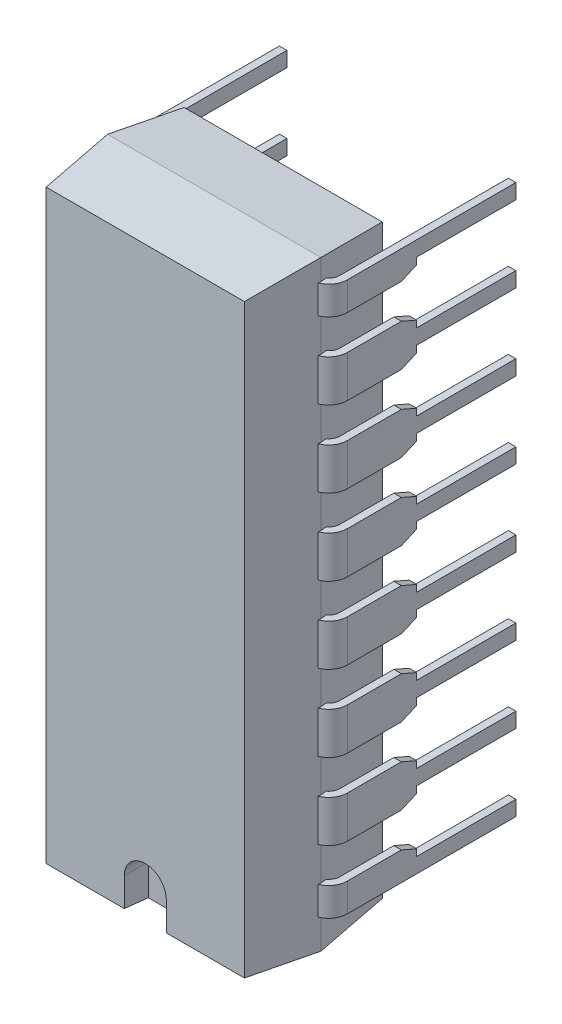
from build123d import *

# Parameters (mm, degrees)
BASIC_SHAPE_DEPTH              = 10
SIDE_PROFILE1_DEPTH            = 4.55
SIDE_PROFILE1_DEPTH_BACK       = 4.55
SIDE_PROFILE2_DEPTH            = 4.55
SIDE_PROFILE2_DEPTH_BACK       = 4.55
LOCATION_MARK_DEPTH            = 0.8
SKETCH6_W                      = 0.25
SKETCH6_H                      = 1.39
PIN_RELIEF_DEPTH               = 1.25
REMAINING_PINS_COUNT           = 8
REMAINING_PINS_PITCH           = 2.54
REMAINING_PINS_COPY_1_SKETCH_W = 0.25
REMAINING_PINS_COPY_1_SKETCH_H = 1.39
REMAINING_PINS_COPY_2_SKETCH_W = 0.25
REMAINING_PINS_COPY_2_SKETCH_H = 1.39
REMAINING_PINS_COPY_3_SKETCH_W = 0.25
REMAINING_PINS_COPY_3_SKETCH_H = 1.39
REMAINING_PINS_COPY_4_SKETCH_W = 0.25
REMAINING_PINS_COPY_4_SKETCH_H = 1.39
REMAINING_PINS_COPY_5_SKETCH_W = 0.25
REMAINING_PINS_COPY_5_SKETCH_H = 1.39
REMAINING_PINS_COPY_6_SKETCH_W = 0.25
REMAINING_PINS_COPY_6_SKETCH_H = 1.39
REMAINING_PINS_COPY_7_SKETCH_W = 0.25
REMAINING_PINS_COPY_7_SKETCH_H = 1.39
REMAINING_PINS_COPY_8_DEPTH    = 1.25
REMAINING_PINS_COPY_9_DEPTH    = 1.25
REMAINING_PINS_COPY_10_DEPTH   = 1.25
REMAINING_PINS_COPY_11_DEPTH   = 1.25
REMAINING_PINS_COPY_12_DEPTH   = 1.25
REMAINING_PINS_COPY_13_DEPTH   = 1.25
REMAINING_PINS_COPY_14_DEPTH   = 1.25
PIN_RELIEF1_DEPTH              = 0.445
PIN_RELIEF2_DEPTH              = 0.445


with BuildPart() as part:
    # Sketch1 → Basic Shape (new body, symmetric)
    with BuildSketch(Plane(origin=(0, 0, 0), x_dir=(1, 0, 0), z_dir=(0, 1, 0))):
        Polygon((-3.3, -5.1), (-3.55, -2.805), (-3.3, -0.51), (3.3, -0.51), (3.55, -2.805), (3.3, -5.1), align=None)
    extrude(amount=BASIC_SHAPE_DEPTH, both=True)

    # Sketch2 → Side Profile1 (cut, two sides)
    with BuildSketch(Plane(origin=(0, 0, 0), x_dir=(0, 0, -1), z_dir=(1, 0, 0))) as side_profile1_sk:
        Polygon((-0.51, 10), (-0.51, 9.75), (-2.805, 10), align=None)
        Polygon((-0.51, -10), (-2.805, -10), (-0.51, -9.75), align=None)
    extrude(amount=SIDE_PROFILE1_DEPTH, mode=Mode.SUBTRACT)
    extrude(side_profile1_sk.sketch, amount=-SIDE_PROFILE1_DEPTH_BACK, mode=Mode.SUBTRACT)

    # Sketch3 → Side Profile2 (cut, two sides)
    with BuildSketch(Plane(origin=(0, 0, 0), x_dir=(0, 0, -1), z_dir=(1, 0, 0))) as side_profile2_sk:
        Polygon((-2.805, 10), (-5.1, 10), (-5.1, 9.75), align=None)
        Polygon((-2.805, -10), (-5.1, -10), (-5.1, -9.75), align=None)
    extrude(amount=SIDE_PROFILE2_DEPTH, mode=Mode.SUBTRACT)
    extrude(side_profile2_sk.sketch, amount=-SIDE_PROFILE2_DEPTH_BACK, mode=Mode.SUBTRACT)

    # Sketch4 → Location Mark (cut)
    with BuildSketch(Plane.XY.offset(5.1)):
        with BuildLine():
            Line((-0.7, -10), (-0.7, -8.8))
            ThreePointArc((-0.7, -8.8), (0, -8.1), (0.7, -8.8))
            Line((0.7, -8.8), (0.7, -10))
            Line((0.7, -10), (-0.7, -10))
        make_face()
    extrude(amount=-LOCATION_MARK_DEPTH, mode=Mode.SUBTRACT)

    # First Pin: sweep along a path in Sketch5
    with BuildLine(Plane(origin=(0, -8.73, 0), x_dir=(1, 0, 0), z_dir=(0, 1, 0))) as first_pin_path:
        Line((0, -2.805), (3.31, -2.805))
        ThreePointArc((3.31, -2.805), (3.663553391, -2.658553391), (3.81, -2.305))
        Line((3.81, -2.305), (3.81, 3.3))
    # Sketch6 → First Pin (sweep)
    with BuildSketch(Plane(origin=(0, 0, 0), x_dir=(0, 0, -1), z_dir=(1, 0, 0))):
        with Locations((-2.805, -8.73)):
            Rectangle(SKETCH6_W, SKETCH6_H)
    first_pin = sweep(path=first_pin_path.line)

    # Sketch7 → Pin Relief (cut, through all)
    with BuildSketch(Plane.ZY.offset(-3.685)):
        Polygon((-3.3, -8.98), (0, -8.98), (0, -9.2025), (0.51, -9.425), (-3.3, -9.425), align=None)
        Polygon((-3.3, -8.48), (0, -8.48), (0, -8.2575), (0.51, -8.035), (-3.3, -8.035), align=None)
    pin_relief = extrude(amount=-PIN_RELIEF_DEPTH, mode=Mode.SUBTRACT)

    # Opp Pin: First Pin, Pin Relief across plane
    add(first_pin.mirror(Plane(origin=(0, 0, 0), x_dir=(0, 0, 1), z_dir=(1, 0, 0))))
    add(pin_relief.mirror(Plane(origin=(0, 0, 0), x_dir=(0, 0, 1), z_dir=(1, 0, 0))), mode=Mode.SUBTRACT)

    # Remaining Pins: First Pin, Pin Relief ×8
    with Locations(*[(0, i * REMAINING_PINS_PITCH, 0) for i in range(1, REMAINING_PINS_COUNT)]):
        add(first_pin)
        add(pin_relief, mode=Mode.SUBTRACT)

    # Remaining Pins copy 1: sweep along a path in Remaining Pins copy 1 path
    with BuildLine(Plane(origin=(0, -6.19, 0), x_dir=(-1, 0, 0), z_dir=(0, 1, 0))) as remaining_pins_copy_1_path:
        Line((0, 2.805), (3.31, 2.805))
        ThreePointArc((3.31, 2.805), (3.663553391, 2.658553391), (3.81, 2.305))
        Line((3.81, 2.305), (3.81, -3.3))
    # Remaining Pins copy 1 sketch → Remaining Pins copy 1 (sweep)
    with BuildSketch(Plane(origin=(0, 2.54, 0), x_dir=(0, 0, -1), z_dir=(-1, 0, 0))):
        with Locations((-2.805, 8.73)):
            Rectangle(REMAINING_PINS_COPY_1_SKETCH_W, REMAINING_PINS_COPY_1_SKETCH_H)
    sweep(path=remaining_pins_copy_1_path.line)

    # Remaining Pins copy 2: sweep along a path in Remaining Pins copy 2 path
    with BuildLine(Plane(origin=(0, -3.65, 0), x_dir=(-1, 0, 0), z_dir=(0, 1, 0))) as remaining_pins_copy_2_path:
        Line((0, 2.805), (3.31, 2.805))
        ThreePointArc((3.31, 2.805), (3.663553391, 2.658553391), (3.81, 2.305))
        Line((3.81, 2.305), (3.81, -3.3))
    # Remaining Pins copy 2 sketch → Remaining Pins copy 2 (sweep)
    with BuildSketch(Plane(origin=(0, 5.08, 0), x_dir=(0, 0, -1), z_dir=(-1, 0, 0))):
        with Locations((-2.805, 8.73)):
            Rectangle(REMAINING_PINS_COPY_2_SKETCH_W, REMAINING_PINS_COPY_2_SKETCH_H)
    sweep(path=remaining_pins_copy_2_path.line)

    # Remaining Pins copy 3: sweep along a path in Remaining Pins copy 3 path
    with BuildLine(Plane(origin=(0, -1.11, 0), x_dir=(-1, 0, 0), z_dir=(0, 1, 0))) as remaining_pins_copy_3_path:
        Line((0, 2.805), (3.31, 2.805))
        ThreePointArc((3.31, 2.805), (3.663553391, 2.658553391), (3.81, 2.305))
        Line((3.81, 2.305), (3.81, -3.3))
    # Remaining Pins copy 3 sketch → Remaining Pins copy 3 (sweep)
    with BuildSketch(Plane(origin=(0, 7.62, 0), x_dir=(0, 0, -1), z_dir=(-1, 0, 0))):
        with Locations((-2.805, 8.73)):
            Rectangle(REMAINING_PINS_COPY_3_SKETCH_W, REMAINING_PINS_COPY_3_SKETCH_H)
    sweep(path=remaining_pins_copy_3_path.line)

    # Remaining Pins copy 4: sweep along a path in Remaining Pins copy 4 path
    with BuildLine(Plane(origin=(0, 1.43, 0), x_dir=(-1, 0, 0), z_dir=(0, 1, 0))) as remaining_pins_copy_4_path:
        Line((0, 2.805), (3.31, 2.805))
        ThreePointArc((3.31, 2.805), (3.663553391, 2.658553391), (3.81, 2.305))
        Line((3.81, 2.305), (3.81, -3.3))
    # Remaining Pins copy 4 sketch → Remaining Pins copy 4 (sweep)
    with BuildSketch(Plane(origin=(0, 10.16, 0), x_dir=(0, 0, -1), z_dir=(-1, 0, 0))):
        with Locations((-2.805, 8.73)):
            Rectangle(REMAINING_PINS_COPY_4_SKETCH_W, REMAINING_PINS_COPY_4_SKETCH_H)
    sweep(path=remaining_pins_copy_4_path.line)

    # Remaining Pins copy 5: sweep along a path in Remaining Pins copy 5 path
    with BuildLine(Plane(origin=(0, 3.97, 0), x_dir=(-1, 0, 0), z_dir=(0, 1, 0))) as remaining_pins_copy_5_path:
        Line((0, 2.805), (3.31, 2.805))
        ThreePointArc((3.31, 2.805), (3.663553391, 2.658553391), (3.81, 2.305))
        Line((3.81, 2.305), (3.81, -3.3))
    # Remaining Pins copy 5 sketch → Remaining Pins copy 5 (sweep)
    with BuildSketch(Plane(origin=(0, 12.7, 0), x_dir=(0, 0, -1), z_dir=(-1, 0, 0))):
        with Locations((-2.805, 8.73)):
            Rectangle(REMAINING_PINS_COPY_5_SKETCH_W, REMAINING_PINS_COPY_5_SKETCH_H)
    sweep(path=remaining_pins_copy_5_path.line)

    # Remaining Pins copy 6: sweep along a path in Remaining Pins copy 6 path
    with BuildLine(Plane(origin=(0, 6.51, 0), x_dir=(-1, 0, 0), z_dir=(0, 1, 0))) as remaining_pins_copy_6_path:
        Line((0, 2.805), (3.31, 2.805))
        ThreePointArc((3.31, 2.805), (3.663553391, 2.658553391), (3.81, 2.305))
        Line((3.81, 2.305), (3.81, -3.3))
    # Remaining Pins copy 6 sketch → Remaining Pins copy 6 (sweep)
    with BuildSketch(Plane(origin=(0, 15.24, 0), x_dir=(0, 0, -1), z_dir=(-1, 0, 0))):
        with Locations((-2.805, 8.73)):
            Rectangle(REMAINING_PINS_COPY_6_SKETCH_W, REMAINING_PINS_COPY_6_SKETCH_H)
    sweep(path=remaining_pins_copy_6_path.line)

    # Remaining Pins copy 7: sweep along a path in Remaining Pins copy 7 path
    with BuildLine(Plane(origin=(0, 9.05, 0), x_dir=(-1, 0, 0), z_dir=(0, 1, 0))) as remaining_pins_copy_7_path:
        Line((0, 2.805), (3.31, 2.805))
        ThreePointArc((3.31, 2.805), (3.663553391, 2.658553391), (3.81, 2.305))
        Line((3.81, 2.305), (3.81, -3.3))
    # Remaining Pins copy 7 sketch → Remaining Pins copy 7 (sweep)
    with BuildSketch(Plane(origin=(0, 17.78, 0), x_dir=(0, 0, -1), z_dir=(-1, 0, 0))):
        with Locations((-2.805, 8.73)):
            Rectangle(REMAINING_PINS_COPY_7_SKETCH_W, REMAINING_PINS_COPY_7_SKETCH_H)
    sweep(path=remaining_pins_copy_7_path.line)

    # Remaining Pins copy 8 sketch → Remaining Pins copy 8 (cut, through all)
    with BuildSketch(Plane(origin=(-3.685, 2.54, 0), x_dir=(0, 0, 1), z_dir=(1, 0, 0))):
        Polygon((-3.3, 8.98), (0, 8.98), (0, 9.2025), (0.51, 9.425), (-3.3, 9.425), align=None)
        Polygon((-3.3, 8.48), (0, 8.48), (0, 8.2575), (0.51, 8.035), (-3.3, 8.035), align=None)
    extrude(amount=-REMAINING_PINS_COPY_8_DEPTH, mode=Mode.SUBTRACT)

    # Remaining Pins copy 9 sketch → Remaining Pins copy 9 (cut, through all)
    with BuildSketch(Plane(origin=(-3.685, 5.08, 0), x_dir=(0, 0, 1), z_dir=(1, 0, 0))):
        Polygon((-3.3, 8.98), (0, 8.98), (0, 9.2025), (0.51, 9.425), (-3.3, 9.425), align=None)
        Polygon((-3.3, 8.48), (0, 8.48), (0, 8.2575), (0.51, 8.035), (-3.3, 8.035), align=None)
    extrude(amount=-REMAINING_PINS_COPY_9_DEPTH, mode=Mode.SUBTRACT)

    # Remaining Pins copy 10 sketch → Remaining Pins copy 10 (cut, through all)
    with BuildSketch(Plane(origin=(-3.685, 7.62, 0), x_dir=(0, 0, 1), z_dir=(1, 0, 0))):
        Polygon((-3.3, 8.98), (0, 8.98), (0, 9.2025), (0.51, 9.425), (-3.3, 9.425), align=None)
        Polygon((-3.3, 8.48), (0, 8.48), (0, 8.2575), (0.51, 8.035), (-3.3, 8.035), align=None)
    extrude(amount=-REMAINING_PINS_COPY_10_DEPTH, mode=Mode.SUBTRACT)

    # Remaining Pins copy 11 sketch → Remaining Pins copy 11 (cut, through all)
    with BuildSketch(Plane(origin=(-3.685, 10.16, 0), x_dir=(0, 0, 1), z_dir=(1, 0, 0))):
        Polygon((-3.3, 8.98), (0, 8.98), (0, 9.2025), (0.51, 9.425), (-3.3, 9.425), align=None)
        Polygon((-3.3, 8.48), (0, 8.48), (0, 8.2575), (0.51, 8.035), (-3.3, 8.035), align=None)
    extrude(amount=-REMAINING_PINS_COPY_11_DEPTH, mode=Mode.SUBTRACT)

    # Remaining Pins copy 12 sketch → Remaining Pins copy 12 (cut, through all)
    with BuildSketch(Plane(origin=(-3.685, 12.7, 0), x_dir=(0, 0, 1), z_dir=(1, 0, 0))):
        Polygon((-3.3, 8.98), (0, 8.98), (0, 9.2025), (0.51, 9.425), (-3.3, 9.425), align=None)
        Polygon((-3.3, 8.48), (0, 8.48), (0, 8.2575), (0.51, 8.035), (-3.3, 8.035), align=None)
    extrude(amount=-REMAINING_PINS_COPY_12_DEPTH, mode=Mode.SUBTRACT)

    # Remaining Pins copy 13 sketch → Remaining Pins copy 13 (cut, through all)
    with BuildSketch(Plane(origin=(-3.685, 15.24, 0), x_dir=(0, 0, 1), z_dir=(1, 0, 0))):
        Polygon((-3.3, 8.98), (0, 8.98), (0, 9.2025), (0.51, 9.425), (-3.3, 9.425), align=None)
        Polygon((-3.3, 8.48), (0, 8.48), (0, 8.2575), (0.51, 8.035), (-3.3, 8.035), align=None)
    extrude(amount=-REMAINING_PINS_COPY_13_DEPTH, mode=Mode.SUBTRACT)

    # Remaining Pins copy 14 sketch → Remaining Pins copy 14 (cut, through all)
    with BuildSketch(Plane(origin=(-3.685, 17.78, 0), x_dir=(0, 0, 1), z_dir=(1, 0, 0))):
        Polygon((-3.3, 8.98), (0, 8.98), (0, 9.2025), (0.51, 9.425), (-3.3, 9.425), align=None)
        Polygon((-3.3, 8.48), (0, 8.48), (0, 8.2575), (0.51, 8.035), (-3.3, 8.035), align=None)
    extrude(amount=-REMAINING_PINS_COPY_14_DEPTH, mode=Mode.SUBTRACT)

    # Sketch9 → Pin Relief1 (cut)
    with BuildSketch(Plane.XZ.offset(9.425)):
        with BuildLine():
            Line((3.935, 0), (3.685, 0))
            Line((3.685, 0), (3.685, 2.305))
            ThreePointArc((3.685, 2.305), (3.64364911, 2.476181984), (3.528715885, 2.609611821))
            Line((3.528715885, 2.609611821), (3.55, 2.805))
            Line((3.55, 2.805), (3.541213578, 2.88565935))
            ThreePointArc((3.541213578, 2.88565935), (3.827268541, 2.655796603), (3.935, 2.305))
            Line((3.935, 2.305), (3.935, 0))
        make_face()
        with BuildLine():
            Line((-3.935, 0), (-3.685, 0))
            Line((-3.685, 0), (-3.685, 2.305))
            ThreePointArc((-3.685, 2.305), (-3.64364911, 2.476181984), (-3.528715885, 2.609611821))
            Line((-3.528715885, 2.609611821), (-3.55, 2.805))
            Line((-3.55, 2.805), (-3.541213578, 2.88565935))
            ThreePointArc((-3.541213578, 2.88565935), (-3.827268541, 2.655796603), (-3.935, 2.305))
            Line((-3.935, 2.305), (-3.935, 0))
        make_face()
    extrude(amount=-PIN_RELIEF1_DEPTH, mode=Mode.SUBTRACT)

    # Sketch10 → Pin Relief2 (cut)
    with BuildSketch(Plane(origin=(0, 9.745, 0), x_dir=(-1, 0, 0), z_dir=(0, 1, 0))):
        with BuildLine():
            Line((3.935, 0), (3.685, 0))
            Line((3.685, 0), (3.685, 2.305))
            ThreePointArc((3.685, 2.305), (3.64364911, 2.476181984), (3.528715885, 2.609611821))
            Line((3.528715885, 2.609611821), (3.55, 2.805))
            Line((3.55, 2.805), (3.541213578, 2.88565935))
            ThreePointArc((3.541213578, 2.88565935), (3.827268541, 2.655796603), (3.935, 2.305))
            Line((3.935, 2.305), (3.935, 0))
        make_face()
        with BuildLine():
            Line((-3.935, 0), (-3.685, 0))
            Line((-3.685, 0), (-3.685, 2.305))
            ThreePointArc((-3.685, 2.305), (-3.64364911, 2.476181984), (-3.528715885, 2.609611821))
            Line((-3.528715885, 2.609611821), (-3.55, 2.805))
            Line((-3.55, 2.805), (-3.541213578, 2.88565935))
            ThreePointArc((-3.541213578, 2.88565935), (-3.827268541, 2.655796603), (-3.935, 2.305))
            Line((-3.935, 2.305), (-3.935, 0))
        make_face()
    extrude(amount=-PIN_RELIEF2_DEPTH, mode=Mode.SUBTRACT)


solid = part.part
